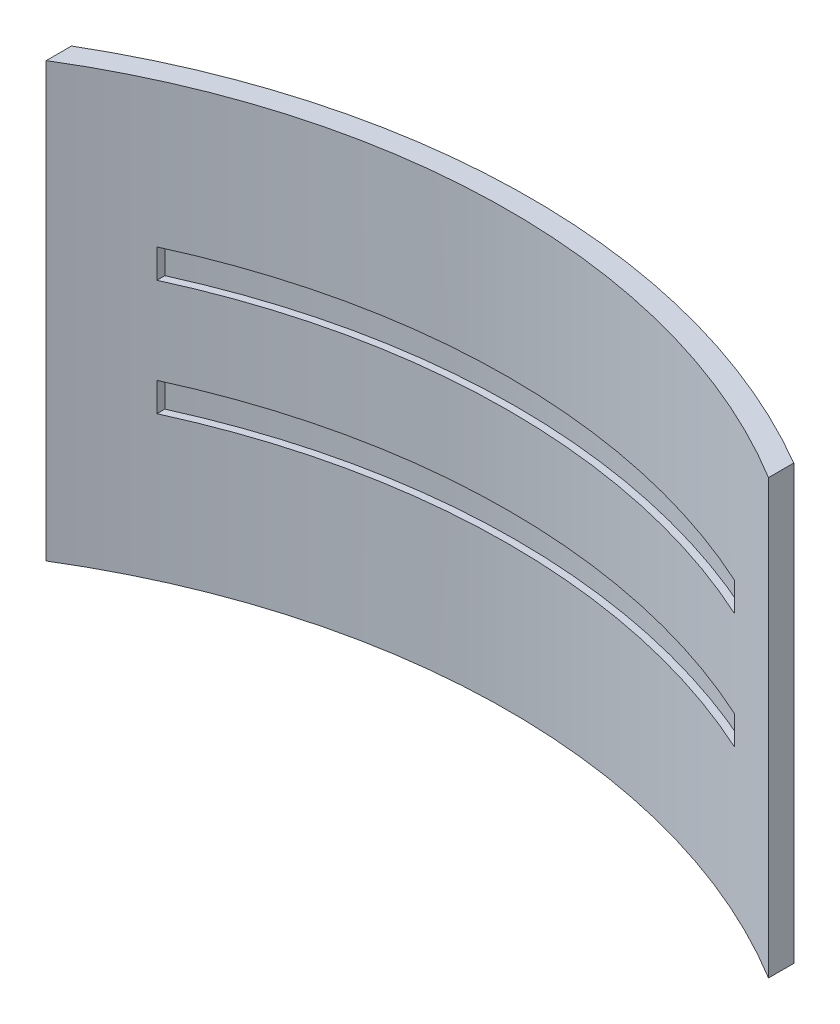
from build123d import *

# Parameters (mm, degrees)
BOSS_EXTRUDE1_DEPTH      = 30
CUT_EXTRUDE28_REACH      = 65.05
CUT_EXTRUDE28_END_RADIUS = 48.5
SKETCH3_W                = 40
SKETCH3_H                = 2
CUT_EXTRUDE29_REACH      = 45.439
CUT_EXTRUDE29_END_RADIUS = 49
SKETCH5_W                = 2
SKETCH5_H                = 20


with BuildPart() as part:
    # Sketch2 → Boss-Extrude1 (new body)
    with BuildSketch(Plane(origin=(0, 0, 0), x_dir=(1, 0, 0), z_dir=(0, 1, 0))):
        with BuildLine():
            Line((-25, 42.722944655), (-25, 40.975602497))
            ThreePointArc((-25, 40.975602497), (0, 48), (25, 40.975602497))
            Line((25, 40.975602497), (25, 42.722944655))
            ThreePointArc((25, 42.722944655), (0, 49.5), (-25, 42.722944655))
        make_face()
    extrude(amount=BOSS_EXTRUDE1_DEPTH)

    # Cut-Extrude28: up to this cylinder (the profile starts inside it)
    cut_extrude28_end = Plane(origin=(0, 15, 0), z_dir=(0, -1, 0)) * Cylinder(CUT_EXTRUDE28_END_RADIUS, 236.1, mode=Mode.PRIVATE)
    # Sketch3 → Cut-Extrude28 (cut, up to the surface)
    with BuildSketch(Plane(origin=(0, 0, 0), x_dir=(-1, 0, 0), z_dir=(0, 0, -1)), mode=Mode.PRIVATE) as cut_extrude28_sk1:
        with Locations((0, 19)):
            Rectangle(SKETCH3_W, SKETCH3_H)
    cut_extrude28_tool1 = extrude(cut_extrude28_sk1.sketch, amount=CUT_EXTRUDE28_REACH, mode=Mode.PRIVATE) & cut_extrude28_end
    add(cut_extrude28_tool1.solids().sort_by_distance((0, 19, 0))[0], mode=Mode.SUBTRACT)
    # Sketch3 → Cut-Extrude28 (cut, up to the surface)
    with BuildSketch(Plane(origin=(0, 0, 0), x_dir=(-1, 0, 0), z_dir=(0, 0, -1)), mode=Mode.PRIVATE) as cut_extrude28_sk2:
        with Locations((0, 11)):
            Rectangle(SKETCH3_W, SKETCH3_H)
    cut_extrude28_tool2 = extrude(cut_extrude28_sk2.sketch, amount=CUT_EXTRUDE28_REACH, mode=Mode.PRIVATE) & cut_extrude28_end
    add(cut_extrude28_tool2.solids().sort_by_distance((0, 11, 0))[0], mode=Mode.SUBTRACT)

    # Cut-Extrude29: up to this cylinder (the profile starts outside it)
    cut_extrude29_end = Plane(origin=(0, 15, 0), z_dir=(0, -1, 0)) * Cylinder(CUT_EXTRUDE29_END_RADIUS, 189.878, mode=Mode.PRIVATE)
    # Sketch5 → Cut-Extrude29 (cut, up to the surface)
    with BuildSketch(Plane.XY.offset(-60), mode=Mode.PRIVATE) as cut_extrude29_sk1:
        with Locations((-4, 15)):
            Rectangle(SKETCH5_W, SKETCH5_H)
    cut_extrude29_tool1 = extrude(cut_extrude29_sk1.sketch, amount=CUT_EXTRUDE29_REACH, mode=Mode.PRIVATE) - cut_extrude29_end
    add(cut_extrude29_tool1.solids().sort_by_distance((-4, 15, -60))[0], mode=Mode.SUBTRACT)
    # Sketch5 → Cut-Extrude29 (cut, up to the surface)
    with BuildSketch(Plane.XY.offset(-60), mode=Mode.PRIVATE) as cut_extrude29_sk2:
        with Locations((4, 15)):
            Rectangle(SKETCH5_W, SKETCH5_H)
    cut_extrude29_tool2 = extrude(cut_extrude29_sk2.sketch, amount=CUT_EXTRUDE29_REACH, mode=Mode.PRIVATE) - cut_extrude29_end
    add(cut_extrude29_tool2.solids().sort_by_distance((4, 15, -60))[0], mode=Mode.SUBTRACT)


solid = part.part
